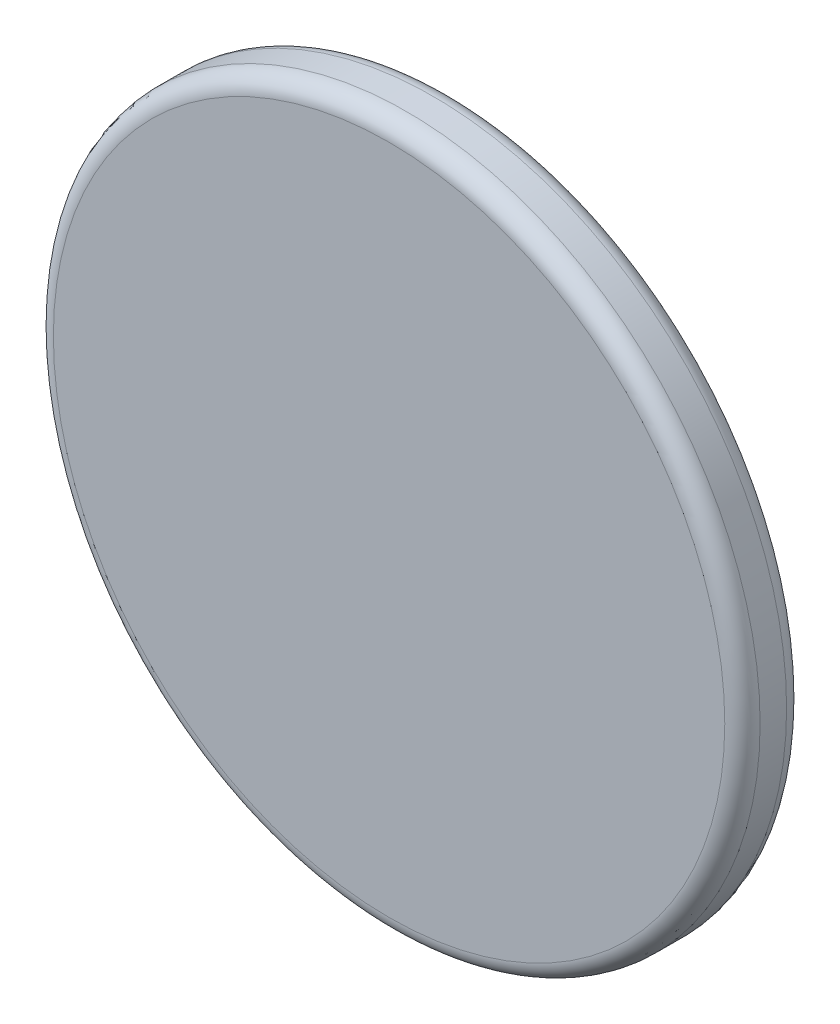
from build123d import *

# Parameters (mm, degrees)
SKETCH1_R           = 40
BOSS_EXTRUDE1_DEPTH = 7
FILLET1_R           = 2
FILLET2_R           = 2


with BuildPart() as part:
    # Sketch1 → Boss-Extrude1 (new body)
    with BuildSketch(Plane.XY):
        Circle(SKETCH1_R)
    extrude(amount=BOSS_EXTRUDE1_DEPTH)

    # Fillet1
    fillet1_edges = [part.edges().sort_by_distance(p)[0] for p in [
        (-40, 0, 0),
    ]]
    fillet(fillet1_edges, radius=FILLET1_R)

    # Fillet2
    fillet2_edges = [part.edges().sort_by_distance(p)[0] for p in [
        (-40, 0, 7),
    ]]
    fillet(fillet2_edges, radius=FILLET2_R)


solid = part.part
